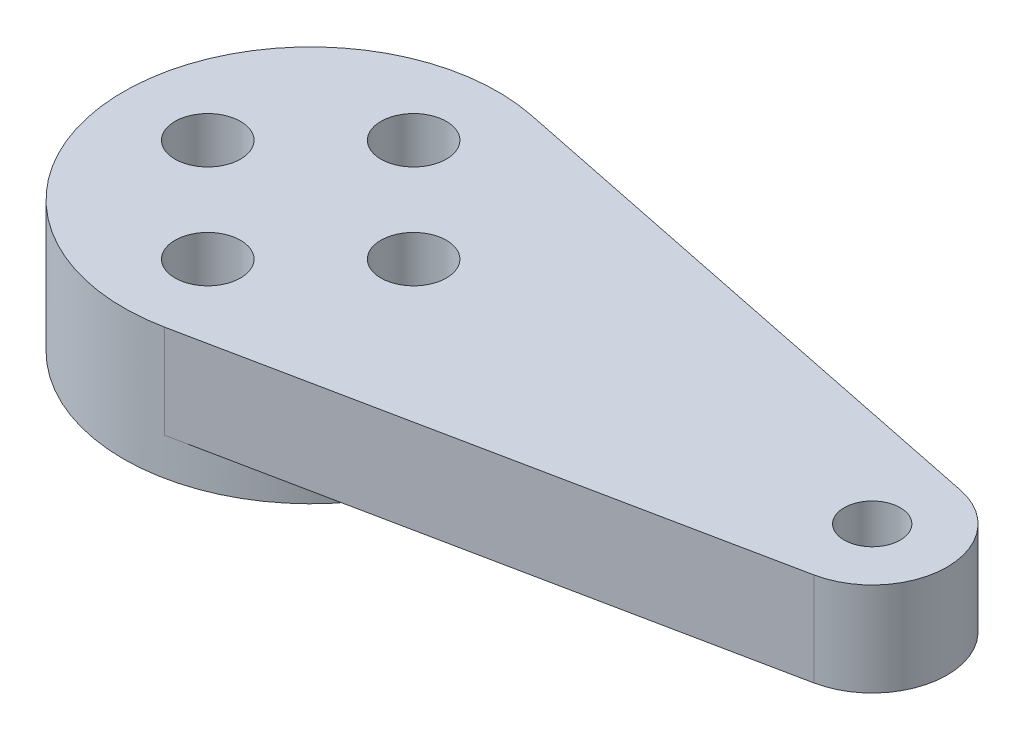
from build123d import *

# Parameters (mm, degrees)
SKETCH1_R           = 10
SKETCH1_R_2         = 1.75
BOSS_EXTRUDE1_DEPTH = 7
SKETCH2_R           = 1.5
BOSS_EXTRUDE2_DEPTH = 5


with BuildPart() as part:
    # Sketch1 → Boss-Extrude1 (new body)
    with BuildSketch(Plane(origin=(0, 0, 0), x_dir=(1, 0, 0), z_dir=(0, 1, 0))):
        Circle(SKETCH1_R)
        with Locations((0, 5.5)):
            Circle(SKETCH1_R_2, mode=Mode.SUBTRACT)
        with Locations((5.5, 0)):
            Circle(SKETCH1_R_2, mode=Mode.SUBTRACT)
        with Locations((0, -5.5)):
            Circle(SKETCH1_R_2, mode=Mode.SUBTRACT)
        with Locations((-5.5, 0)):
            Circle(SKETCH1_R_2, mode=Mode.SUBTRACT)
    extrude(amount=BOSS_EXTRUDE1_DEPTH)

    # Sketch2 → Boss-Extrude2 (add)
    with BuildSketch(Plane(origin=(0, 7, 0), x_dir=(1, 0, 0), z_dir=(0, 1, 0))):
        with BuildLine():
            Line((2, 9.797958971), (30.8, 3.919183588))
            ThreePointArc((30.8, 3.919183588), (34, 0), (30.8, -3.919183588))
            Line((30.8, -3.919183588), (2, -9.797958971))
            ThreePointArc((2, -9.797958971), (10, 0), (2, 9.797958971))
        make_face()
        with Locations((30, 0)):
            Circle(SKETCH2_R, mode=Mode.SUBTRACT)
    extrude(amount=-BOSS_EXTRUDE2_DEPTH)


solid = part.part
